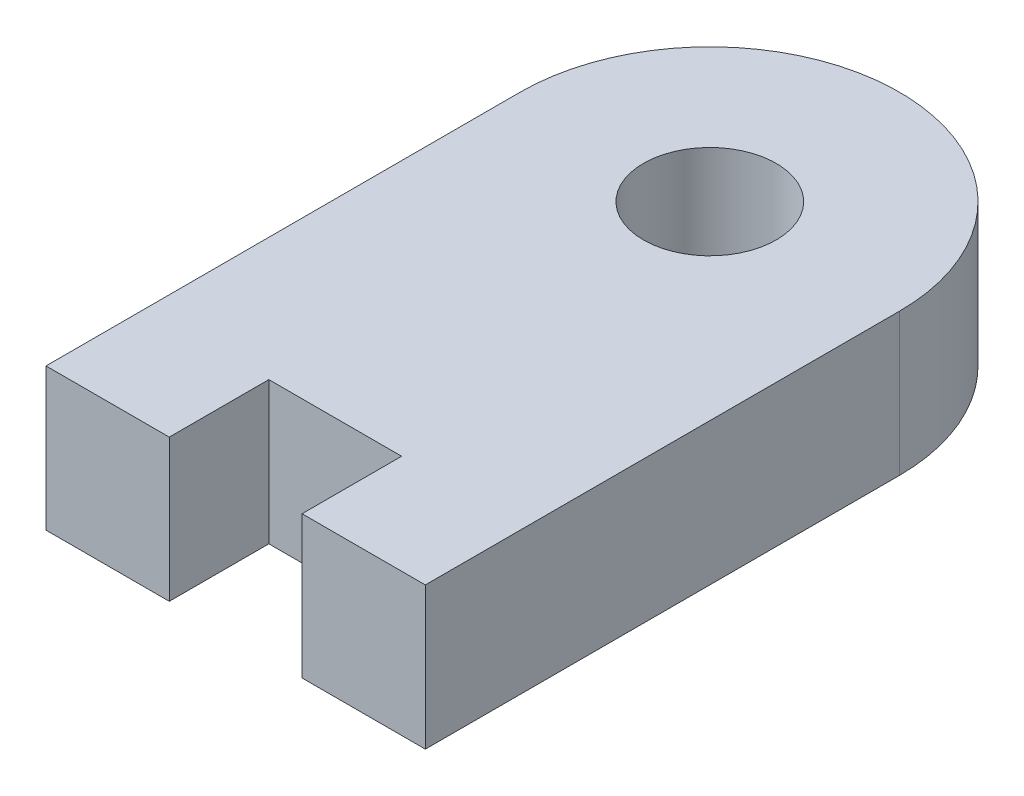
from build123d import *

# Parameters (mm, degrees)
SKETCH1_R           = 1.4
BOSS_EXTRUDE1_DEPTH = 3


with BuildPart() as part:
    # Sketch1 → Boss-Extrude1 (new body)
    with BuildSketch(Plane(origin=(0, 0, 0), x_dir=(1, 0, 0), z_dir=(0, 1, 0))):
        with BuildLine():
            Line((-4, 0), (-4, -10))
            Line((-4, -10), (-1.4, -10))
            Line((-1.4, -10), (-1.4, -7.9))
            Line((-1.4, -7.9), (1.4, -7.9))
            Line((1.4, -7.9), (1.4, -10))
            Line((1.4, -10), (4, -10))
            Line((4, -10), (4, 0))
            ThreePointArc((4, 0), (0, 4), (-4, 0))
        make_face()
        Circle(SKETCH1_R, mode=Mode.SUBTRACT)
    extrude(amount=BOSS_EXTRUDE1_DEPTH)


solid = part.part
